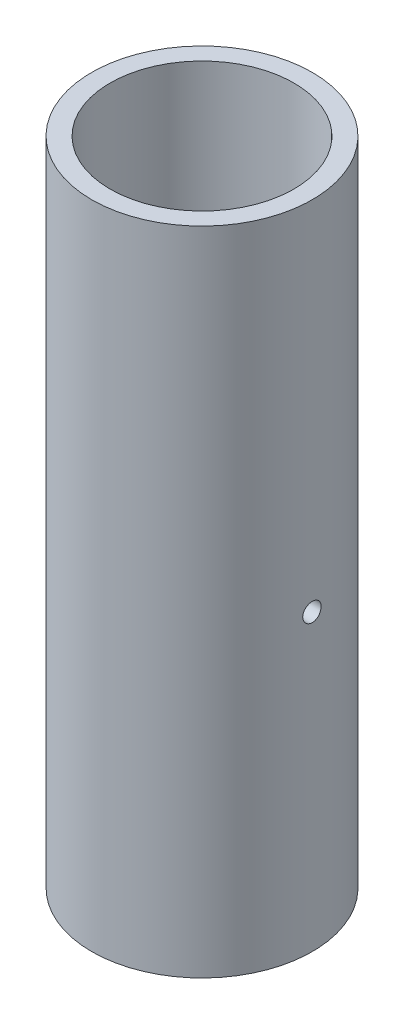
from build123d import *

# Parameters (mm, degrees)
SKETCH1_R      = 9.525
SKETCH1_R_2    = 7.9375
EXTRUDE1_DEPTH = 56.229999986


with BuildPart() as part:
    # Sketch1 → Extrude1 (new body)
    with BuildSketch(Plane(origin=(0, 0, 0), x_dir=(1, 0, 0), z_dir=(0, 1, 0))):
        with Locations(Location((0, 0, 0), (0, 0, 270))):  # turned: the seam where the file's is
            Circle(SKETCH1_R)
        with Locations(Location((0, 0, 0), (0, 0, 270))):  # turned: the seam where the file's is
            Circle(SKETCH1_R_2, mode=Mode.SUBTRACT)
    extrude(amount=EXTRUDE1_DEPTH)

    # Sketch3 → 1/16 (0.0625) Diameter Hole1 (revolve, cut)
    with BuildSketch(Plane.ZX.offset(25.4)):
        Polygon((0, 0), (0, 10.001933116), (0.79375, 9.525), (0.79375, 0), align=None)
    revolve(axis=Axis((-6.35, 25.4, 0), (1, 0, 0)), mode=Mode.SUBTRACT)


solid = part.part
